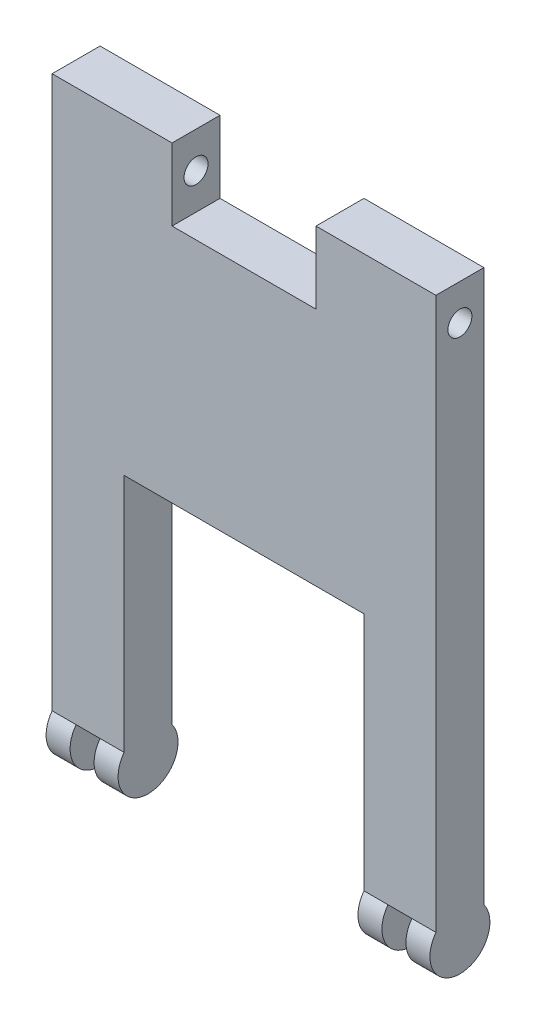
from build123d import *

# Parameters (mm, degrees)
BOSS_EXTRUDE2_DEPTH = 20
SKETCH2_R           = 12.5
CUT_EXTRUDE1_DEPTH  = 80
SKETCH3_R           = 12.5
BOSS_EXTRUDE3_DEPTH = 10
SKETCH4_R           = 12.5
BOSS_EXTRUDE4_DEPTH = 10
CUT_EXTRUDE2_REACH  = 162
SKETCH5_R           = 5
SKETCH6_W           = 60
SKETCH6_H           = 20
CUT_EXTRUDE3_DEPTH  = 30


with BuildPart() as part:
    # Sketch1 → Boss-Extrude2 (new body)
    with BuildSketch(Plane.XY):
        Polygon((50, -115), (80, -115), (80, 115), (-80, 115), (-80, -115), (-50, -115), (-50, -15), (50, -15), align=None)
    extrude(amount=-BOSS_EXTRUDE2_DEPTH)

    # Sketch2 → Cut-Extrude1 (cut, symmetric)
    with BuildSketch(Plane(origin=(0, 0, 0), x_dir=(0, 0, -1), z_dir=(1, 0, 0))):
        with Locations((10, -122.5)):
            Circle(SKETCH2_R)
    extrude(amount=CUT_EXTRUDE1_DEPTH, both=True, mode=Mode.SUBTRACT)

    # Sketch3 → Boss-Extrude3 (add)
    with BuildSketch(Plane(origin=(80, 0, 0), x_dir=(0, 0, -1), z_dir=(1, 0, 0))):
        with Locations((10, -122.5)):
            Circle(SKETCH3_R)
    boss_extrude3 = extrude(amount=-BOSS_EXTRUDE3_DEPTH)

    # Mirror1: Boss-Extrude3 across plane
    add(boss_extrude3.mirror(Plane(origin=(0, 0, 0), x_dir=(0, 0, 1), z_dir=(1, 0, 0))))

    # Sketch4 → Boss-Extrude4 (add)
    with BuildSketch(Plane.ZY.offset(-50)):
        with Locations((-10, -122.5)):
            Circle(SKETCH4_R)
    boss_extrude4 = extrude(amount=-BOSS_EXTRUDE4_DEPTH)

    # Mirror2: Boss-Extrude4 across plane
    add(boss_extrude4.mirror(Plane(origin=(0, 0, 0), x_dir=(0, 0, 1), z_dir=(1, 0, 0))))

    # Sketch5 → Cut-Extrude2 (cut, up to next)
    with BuildSketch(Plane(origin=(80, 0, 0), x_dir=(0, 0, -1), z_dir=(1, 0, 0)), mode=Mode.PRIVATE) as cut_extrude2_sk1:
        with Locations((10, 100)):
            Circle(SKETCH5_R)
    cut_extrude2_tool1 = extrude(cut_extrude2_sk1.sketch, amount=-CUT_EXTRUDE2_REACH, mode=Mode.PRIVATE) & part.part
    add(cut_extrude2_tool1.solids().sort_by_distance((80, 100, -10))[0], mode=Mode.SUBTRACT)

    # Sketch6 → Cut-Extrude3 (cut)
    with BuildSketch(Plane(origin=(0, 115, 0), x_dir=(1, 0, 0), z_dir=(0, 1, 0))):
        with Locations((0, 10)):
            Rectangle(SKETCH6_W, SKETCH6_H)
    extrude(amount=-CUT_EXTRUDE3_DEPTH, mode=Mode.SUBTRACT)


solid = part.part
